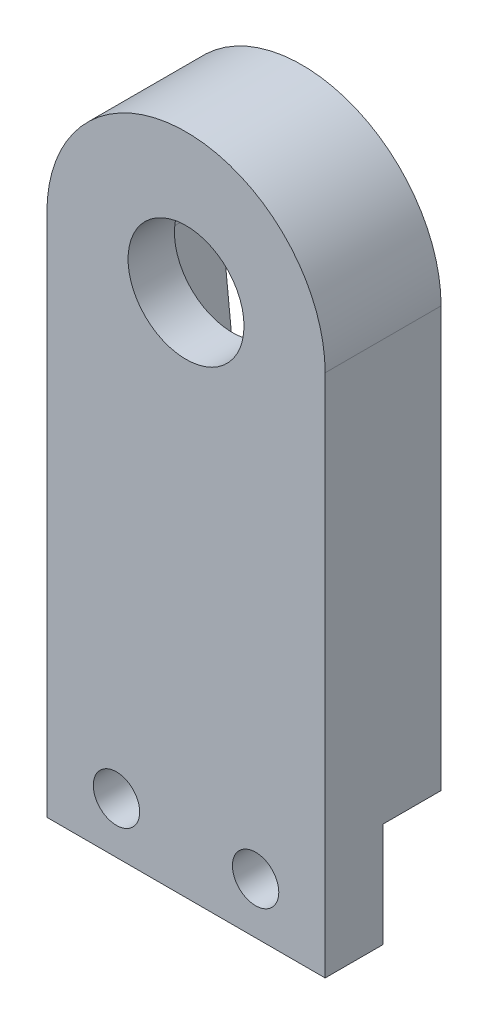
from build123d import *

# Parameters (mm, degrees)
SKETCH1_W           = 11.999998241
SKETCH1_H           = 22.605046118
BOSS_EXTRUDE1_DEPTH = 5
BOSS_EXTRUDE2_DEPTH = 5
SKETCH4_R           = 2.5
CUT_EXTRUDE3_DEPTH  = 5
CUT_EXTRUDE7_DEPTH  = 3
SKETCH10_W          = 11.999998241
SKETCH10_H          = 4.5
CUT_EXTRUDE8_DEPTH  = 2.5
SKETCH12_R          = 1
CUT_EXTRUDE9_DEPTH  = 5


with BuildPart() as part:
    # Sketch1 → Boss-Extrude1 (new body)
    with BuildSketch(Plane.XY):
        with Locations((-37.429383025, 291.690953332)):
            Rectangle(SKETCH1_W, SKETCH1_H)
    extrude(amount=BOSS_EXTRUDE1_DEPTH)

    # Sketch3 → Boss-Extrude2 (add)
    with BuildSketch(Plane.XY):
        with BuildLine():
            Line((-31.429383904, 302.993476391), (-43.429382145, 302.993476391))
            ThreePointArc((-43.429382145, 302.993476391), (-37.429383025, 308.993475512), (-31.429383904, 302.993476391))
        make_face()
    extrude(amount=BOSS_EXTRUDE2_DEPTH)

    # Sketch4 → Cut-Extrude3 (cut)
    with BuildSketch(Plane.XY):
        with Locations((-37.429383025, 302.993476391)):
            Circle(SKETCH4_R)
    extrude(amount=CUT_EXTRUDE3_DEPTH, mode=Mode.SUBTRACT)

    # Sketch6 → Cut-Extrude7 (cut)
    with BuildSketch(Plane.XY):
        with BuildLine():
            Line((-33.809082583, 303.064405918), (-35.29156372, 288.661777973))
            ThreePointArc((-35.29156372, 288.661777973), (-37.429381162, 286.732713757), (-39.567198604, 288.661777973))
            Line((-39.567198604, 288.661777973), (-40.961969567, 302.198216304))
            ThreePointArc((-40.961969567, 302.198216304), (-37.864692735, 306.588210281), (-33.809082583, 303.064405918))
        make_face()
    extrude(amount=CUT_EXTRUDE7_DEPTH, mode=Mode.SUBTRACT)

    # Sketch10 → Cut-Extrude8 (cut)
    with BuildSketch(Plane.XY):
        with Locations((-37.429383025, 282.638430273)):
            Rectangle(SKETCH10_W, SKETCH10_H)
    extrude(amount=CUT_EXTRUDE8_DEPTH, mode=Mode.SUBTRACT)

    # Sketch12 → Cut-Extrude9 (cut)
    with BuildSketch(Plane.XY):
        with Locations((-34.429383904, 282.588430273)):
            Circle(SKETCH12_R)
        with Locations((-40.429382145, 282.588430273)):
            Circle(SKETCH12_R)
    extrude(amount=CUT_EXTRUDE9_DEPTH, mode=Mode.SUBTRACT)


solid = part.part
